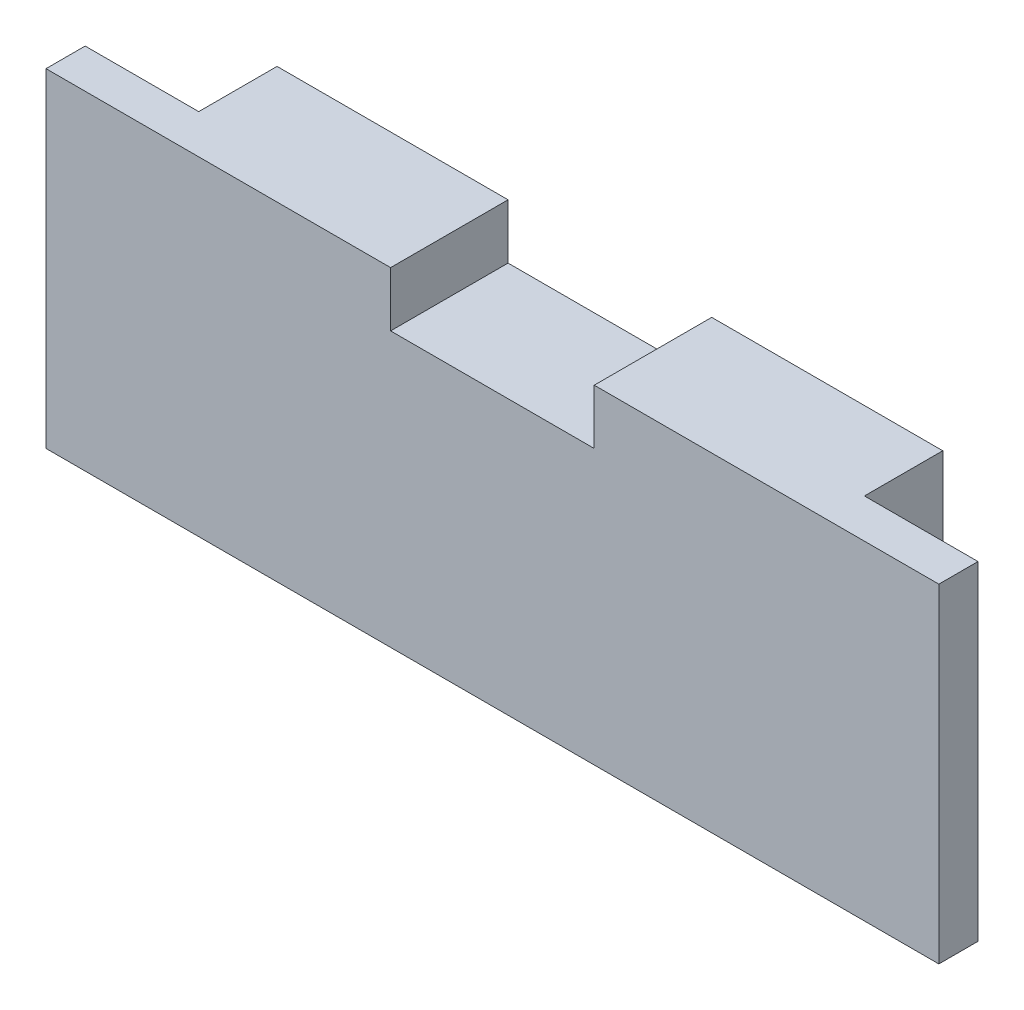
from build123d import *

# Parameters (mm, degrees)
SKETCH1_W           = 57
SKETCH1_H           = 21
BOSS_EXTRUDE1_DEPTH = 2.5
SKETCH2_W           = 42.5
SKETCH2_H           = 21
BOSS_EXTRUDE2_DEPTH = 5
SKETCH3_W           = 13
SKETCH3_H           = 3.5
CUT_EXTRUDE1_DEPTH  = 8.5


with BuildPart() as part:
    # Sketch1 → Boss-Extrude1 (new body)
    with BuildSketch(Plane.XY):
        Rectangle(SKETCH1_W, SKETCH1_H)
    extrude(amount=BOSS_EXTRUDE1_DEPTH)

    # Sketch2 → Boss-Extrude2 (add)
    with BuildSketch(Plane(origin=(0, 0, 0), x_dir=(-1, 0, 0), z_dir=(0, 0, -1))):
        Rectangle(SKETCH2_W, SKETCH2_H)
    extrude(amount=BOSS_EXTRUDE2_DEPTH)

    # Sketch3 → Cut-Extrude1 (cut, through all)
    with BuildSketch(Plane.XY.offset(2.5)):
        with Locations((0, 8.75)):
            Rectangle(SKETCH3_W, SKETCH3_H)
    extrude(amount=-CUT_EXTRUDE1_DEPTH, mode=Mode.SUBTRACT)


solid = part.part
